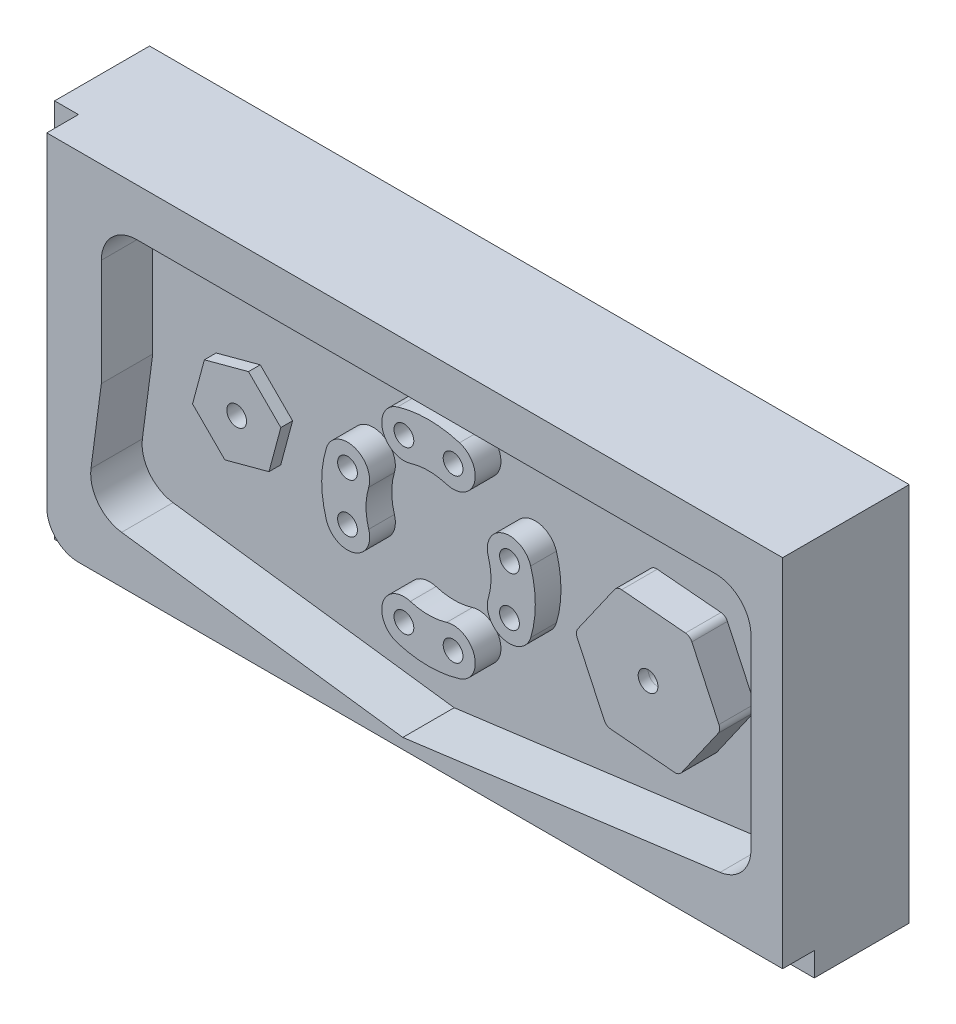
from build123d import *

# Parameters (mm, degrees)
SKETCH1_W                                 = 152.4
SKETCH1_H                                 = 76.2
BOSS_EXTRUDE1_DEPTH                       = 25.4
SKETCH2_OUTSIDE_W                         = 188.854
SKETCH2_OUTSIDE_H                         = 112.654
CUT_EXTRUDE1_DEPTH                        = 6.35
CUT_EXTRUDE3_DEPTH                        = 10.3124
BOSS_EXTRUDE3_DEPTH                       = 5.1562
SKETCH11_R                                = 1.9812
BOSS_EXTRUDE4_DEPTH                       = 2.3622
SKETCH12_R                                = 1.9812
BOSS_EXTRUDE5_DEPTH                       = 7.1374
SKETCH9_W                                 = 1.984375
SKETCH9_H                                 = 20.2438
F_5_32_0_15625_DIAMETER_HOLE1_AT_2_COUNT  = 2
F_5_32_0_15625_DIAMETER_HOLE1_AT_2_PITCH  = 9.865104057
F_5_32_0_15625_DIAMETER_HOLE1_AT_3_COUNT  = 2
F_5_32_0_15625_DIAMETER_HOLE1_AT_3_PITCH  = 24.013204868
F_5_32_0_15625_DIAMETER_HOLE1_AT_4_COUNT  = 2
F_5_32_0_15625_DIAMETER_HOLE1_AT_4_PITCH  = 29.953363952
F_5_32_0_15625_DIAMETER_HOLE1_AT_5_COUNT  = 2
F_5_32_0_15625_DIAMETER_HOLE1_AT_5_PITCH  = 33.9598
F_5_32_0_15625_DIAMETER_HOLE1_AT_6_COUNT  = 2
F_5_32_0_15625_DIAMETER_HOLE1_AT_6_PITCH  = 32.495349482
F_5_32_0_15625_DIAMETER_HOLE1_AT_7_COUNT  = 2
F_5_32_0_15625_DIAMETER_HOLE1_AT_7_PITCH  = 24.013204868
F_5_32_0_15625_DIAMETER_HOLE1_AT_8_COUNT  = 2
F_5_32_0_15625_DIAMETER_HOLE1_AT_8_PITCH  = 16.002
F_5_32_0_15625_DIAMETER_HOLE1_AT_9_COUNT  = 2
F_5_32_0_15625_DIAMETER_HOLE1_AT_9_PITCH  = 25.499228315
F_5_32_0_15625_DIAMETER_HOLE1_AT_10_COUNT = 2
F_5_32_0_15625_DIAMETER_HOLE1_AT_10_PITCH = 62.467521


with BuildPart() as part:
    # Sketch1 → Boss-Extrude1 (new body)
    with BuildSketch(Plane.XY):
        Rectangle(SKETCH1_W, SKETCH1_H)
    extrude(amount=BOSS_EXTRUDE1_DEPTH)

    # Sketch2 outside → Cut-Extrude1 (cut)
    with BuildSketch(Plane.XY.offset(25.4)):
        Rectangle(SKETCH2_OUTSIDE_W, SKETCH2_OUTSIDE_H)
        with BuildLine():
            Line((-71.4248, 38.1), (76.2, 38.1))
            Line((76.2, 38.1), (76.2, -33.3248))
            Line((76.2, -33.3248), (-65.0748, -33.3248))
            ThreePointArc((-65.0748, -33.3248), (-69.564928061, -31.464928061), (-71.4248, -26.9748))
            Line((-71.4248, -26.9748), (-71.4248, 38.1))
        make_face(mode=Mode.SUBTRACT)
    extrude(amount=-CUT_EXTRUDE1_DEPTH, mode=Mode.SUBTRACT)

    # Sketch5 → Cut-Extrude3 (cut)
    with BuildSketch(Plane.XY.offset(25.4)):
        with BuildLine():
            Line((-53.34, 28.575), (62.7126, 28.575))
            ThreePointArc((62.7126, 28.575), (67.75950394, 26.48450394), (69.85, 21.4376))
            Line((69.85, 21.4376), (69.85, -15.769127551))
            ThreePointArc((69.85, -15.769127551), (68.078781442, -20.475142372), (63.644217644, -22.845466105))
            Line((63.644217644, -22.845466105), (0, -31.224386314))
            Line((0, -31.224386314), (-56.411435655, -23.797679918))
            ThreePointArc((-56.411435655, -23.797679918), (-61.142298141, -21.066315188), (-62.556156564, -15.78972372))
            Line((-62.556156564, -15.78972372), (-60.4774, 0))
            Line((-60.4774, 0), (-60.4774, 21.4376))
            ThreePointArc((-60.4774, 21.4376), (-58.38690394, 26.48450394), (-53.34, 28.575))
        make_face()
    extrude(amount=-CUT_EXTRUDE3_DEPTH, mode=Mode.SUBTRACT)

    # Sketch6 → Boss-Extrude3 (add)
    with BuildSketch(Plane.XY.offset(15.0876)):
        with BuildLine():
            ThreePointArc((-20.500992736, 6.223796015), (-21.4249, 0), (-20.500992736, -6.223796015))
            ThreePointArc((-20.500992736, -6.223796015), (-14.956430755, -9.185870024), (-11.994356746, -3.641308042))
            ThreePointArc((-11.994356746, -3.641308042), (-12.5349, 0), (-11.994356746, 3.641308042))
            ThreePointArc((-11.994356746, 3.641308042), (-14.956430755, 9.185870024), (-20.500992736, 6.223796015))
        make_face()
        with BuildLine():
            ThreePointArc((20.500992736, -6.223796015), (21.4249, 0), (20.500992736, 6.223796015))
            ThreePointArc((20.500992736, 6.223796015), (14.956430755, 9.185870024), (11.994356746, 3.641308042))
            ThreePointArc((11.994356746, 3.641308042), (12.5349, 0), (11.994356746, -3.641308042))
            ThreePointArc((11.994356746, -3.641308042), (14.956430755, -9.185870024), (20.500992736, -6.223796015))
        make_face()
        with BuildLine():
            ThreePointArc((-6.223796015, -20.500992736), (0, -21.4249), (6.223796015, -20.500992736))
            ThreePointArc((6.223796015, -20.500992736), (9.185870024, -14.956430755), (3.641308042, -11.994356746))
            ThreePointArc((3.641308042, -11.994356746), (0, -12.5349), (-3.641308042, -11.994356746))
            ThreePointArc((-3.641308042, -11.994356746), (-9.185870024, -14.956430755), (-6.223796015, -20.500992736))
        make_face()
        with BuildLine():
            ThreePointArc((6.223796015, 20.500992736), (0, 21.4249), (-6.223796015, 20.500992736))
            ThreePointArc((-6.223796015, 20.500992736), (-9.185870024, 14.956430755), (-3.641308042, 11.994356746))
            ThreePointArc((-3.641308042, 11.994356746), (0, 12.5349), (3.641308042, 11.994356746))
            ThreePointArc((3.641308042, 11.994356746), (9.185870024, 14.956430755), (6.223796015, 20.500992736))
        make_face()
    extrude(amount=BOSS_EXTRUDE3_DEPTH)

    # Sketch11 → Boss-Extrude4 (add)
    with BuildSketch(Plane.XY.offset(15.0876)):
        Polygon((-38.90278116, 8.902536881), (-47.755912042, 6.530347611), (-50.128101312, -2.32278327), (-43.647159701, -8.803724881), (-34.794028819, -6.431535611), (-32.421839549, 2.42159527), align=None)
        with Locations((-41.274970431, 0.049406)):
            Circle(SKETCH11_R, mode=Mode.SUBTRACT)
    extrude(amount=BOSS_EXTRUDE4_DEPTH)

    # Sketch12 → Boss-Extrude5 (add)
    with BuildSketch(Plane.XY.offset(15.0876)):
        with BuildLine():
            Line((52.743870809, -12.545946722), (60.112191116, -2.022894761))
            ThreePointArc((60.112191116, -2.022894761), (60.390997888, -1.256879453), (60.24944398, -0.454087351))
            Line((60.24944398, -0.454087351), (54.820373811, 11.188591199))
            ThreePointArc((54.820373811, 11.188591199), (54.29638848, 11.8130526), (53.530373171, 12.091859371))
            Line((53.530373171, 12.091859371), (40.732982694, 13.21148596))
            ThreePointArc((40.732982694, 13.21148596), (39.930190592, 13.069932053), (39.305729191, 12.545946722))
            Line((39.305729191, 12.545946722), (31.937408884, 2.022894761))
            ThreePointArc((31.937408884, 2.022894761), (31.658602112, 1.256879453), (31.80015602, 0.454087351))
            Line((31.80015602, 0.454087351), (37.229226189, -11.188591199))
            ThreePointArc((37.229226189, -11.188591199), (37.75321152, -11.8130526), (38.519226829, -12.091859371))
            Line((38.519226829, -12.091859371), (51.316617306, -13.21148596))
            ThreePointArc((51.316617306, -13.21148596), (52.119409408, -13.069932053), (52.743870809, -12.545946722))
        make_face()
        with Locations((46.0248, 0)):
            Circle(SKETCH12_R, mode=Mode.SUBTRACT)
    extrude(amount=BOSS_EXTRUDE5_DEPTH)

    # Sketch9 → 5/32 (0.15625) Diameter Hole1 (revolve, cut)
    with BuildSketch(Plane(origin=(-16.247674741, 4.932552029, 20.2438), x_dir=(0, -1, 0), z_dir=(1, 0, 0))):
        with Locations((0.9921875, 10.1219)):
            Rectangle(SKETCH9_W, SKETCH9_H)
    f_5_32_0_15625_diameter_hole1 = revolve(axis=Axis((-16.247674741, 4.932552029, 26.5938), (0, 0, -1)), mode=Mode.SUBTRACT)

    # 5/32 (0.15625) Diameter Hole1 at 2: 5/32 (0.15625) Diameter Hole1 ×2
    with Locations(*[(0, -i * F_5_32_0_15625_DIAMETER_HOLE1_AT_2_PITCH, 0) for i in range(1, F_5_32_0_15625_DIAMETER_HOLE1_AT_2_COUNT)]):
        add(f_5_32_0_15625_diameter_hole1, mode=Mode.SUBTRACT)

    # 5/32 (0.15625) Diameter Hole1 at 3: 5/32 (0.15625) Diameter Hole1 ×2
    with Locations(*[Vector(0.471204188, -0.882024157, 0) * (i * F_5_32_0_15625_DIAMETER_HOLE1_AT_3_PITCH) for i in range(1, F_5_32_0_15625_DIAMETER_HOLE1_AT_3_COUNT)]):
        add(f_5_32_0_15625_diameter_hole1, mode=Mode.SUBTRACT)

    # 5/32 (0.15625) Diameter Hole1 at 4: 5/32 (0.15625) Diameter Hole1 ×2
    with Locations(*[Vector(0.707106781, -0.707106781, 0) * (i * F_5_32_0_15625_DIAMETER_HOLE1_AT_4_PITCH) for i in range(1, F_5_32_0_15625_DIAMETER_HOLE1_AT_4_COUNT)]):
        add(f_5_32_0_15625_diameter_hole1, mode=Mode.SUBTRACT)

    # 5/32 (0.15625) Diameter Hole1 at 5: 5/32 (0.15625) Diameter Hole1 ×2
    with Locations(*[Vector(0.956876939, -0.290493585, 0) * (i * F_5_32_0_15625_DIAMETER_HOLE1_AT_5_PITCH) for i in range(1, F_5_32_0_15625_DIAMETER_HOLE1_AT_5_COUNT)]):
        add(f_5_32_0_15625_diameter_hole1, mode=Mode.SUBTRACT)

    # 5/32 (0.15625) Diameter Hole1 at 6: 5/32 (0.15625) Diameter Hole1 ×2
    with Locations(*[(i * F_5_32_0_15625_DIAMETER_HOLE1_AT_6_PITCH, 0, 0) for i in range(1, F_5_32_0_15625_DIAMETER_HOLE1_AT_6_COUNT)]):
        add(f_5_32_0_15625_diameter_hole1, mode=Mode.SUBTRACT)

    # 5/32 (0.15625) Diameter Hole1 at 7: 5/32 (0.15625) Diameter Hole1 ×2
    with Locations(*[Vector(0.882024157, 0.471204188, 0) * (i * F_5_32_0_15625_DIAMETER_HOLE1_AT_7_PITCH) for i in range(1, F_5_32_0_15625_DIAMETER_HOLE1_AT_7_COUNT)]):
        add(f_5_32_0_15625_diameter_hole1, mode=Mode.SUBTRACT)

    # 5/32 (0.15625) Diameter Hole1 at 8: 5/32 (0.15625) Diameter Hole1 ×2
    with Locations(*[Vector(0.707106781, 0.707106781, 0) * (i * F_5_32_0_15625_DIAMETER_HOLE1_AT_8_PITCH) for i in range(1, F_5_32_0_15625_DIAMETER_HOLE1_AT_8_COUNT)]):
        add(f_5_32_0_15625_diameter_hole1, mode=Mode.SUBTRACT)

    # 5/32 (0.15625) Diameter Hole1 at 9: 5/32 (0.15625) Diameter Hole1 ×2
    with Locations(*[Vector(-0.981492278, -0.191501718, 0) * (i * F_5_32_0_15625_DIAMETER_HOLE1_AT_9_PITCH) for i in range(1, F_5_32_0_15625_DIAMETER_HOLE1_AT_9_COUNT)]):
        add(f_5_32_0_15625_diameter_hole1, mode=Mode.SUBTRACT)

    # 5/32 (0.15625) Diameter Hole1 at 10: 5/32 (0.15625) Diameter Hole1 ×2
    with Locations(*[Vector(0.996877637, -0.078961866, 0) * (i * F_5_32_0_15625_DIAMETER_HOLE1_AT_10_PITCH) for i in range(1, F_5_32_0_15625_DIAMETER_HOLE1_AT_10_COUNT)]):
        add(f_5_32_0_15625_diameter_hole1, mode=Mode.SUBTRACT)


solid = part.part
